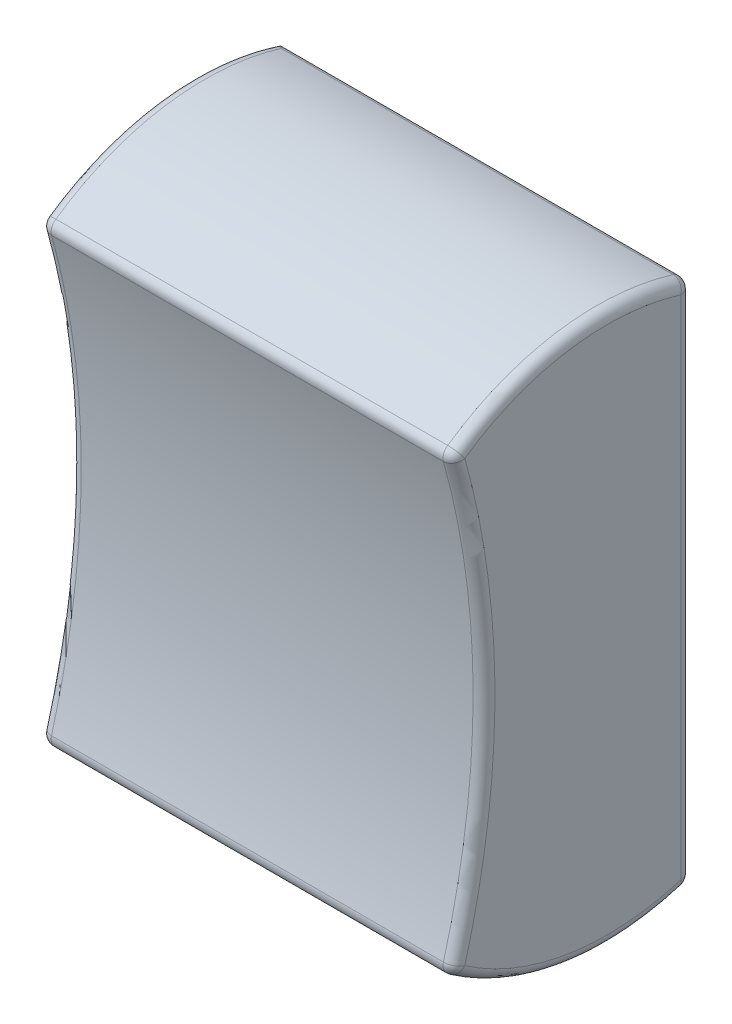
from build123d import *

# Parameters (mm, degrees)
BOSS_EXTRUDE2_DEPTH = 9.5
FILLET1_R           = 0.5


with BuildPart() as part:
    # Sketch2 → Boss-Extrude2 (new body, symmetric)
    with BuildSketch(Plane(origin=(0, 0, 0), x_dir=(0, 0, -1), z_dir=(1, 0, 0))):
        with BuildLine():
            Line((0, 12), (0, -12))
            ThreePointArc((0, -12), (-5.710285596, -12.497714363), (-11, -10.29))
            ThreePointArc((-11, -10.29), (-9.540341867, 0), (-11, 10.29))
            ThreePointArc((-11, 10.29), (-5.710285596, 12.497714363), (0, 12))
        make_face()
    extrude(amount=BOSS_EXTRUDE2_DEPTH, both=True)

    # Fillet1
    fillet1_edges = [part.edges().sort_by_distance(p)[0] for p in [
        (9.5, 12.497714363, 5.710285596),
        (9.5, 0, 9.540341867),
        (9.5, -12.497714363, 5.710285596),
        (-9.5, 0, 9.540341867),
        (-9.5, 12.497714363, 5.710285596),
        (-9.5, -12.497714363, 5.710285596),
        (0, -10.29, 11),
        (0, 10.29, 11),
        (0, 12, 0),
        (0, -12, 0),
        (9.5, 0, 0),
    ]]
    fillet(fillet1_edges, radius=FILLET1_R)


solid = part.part
